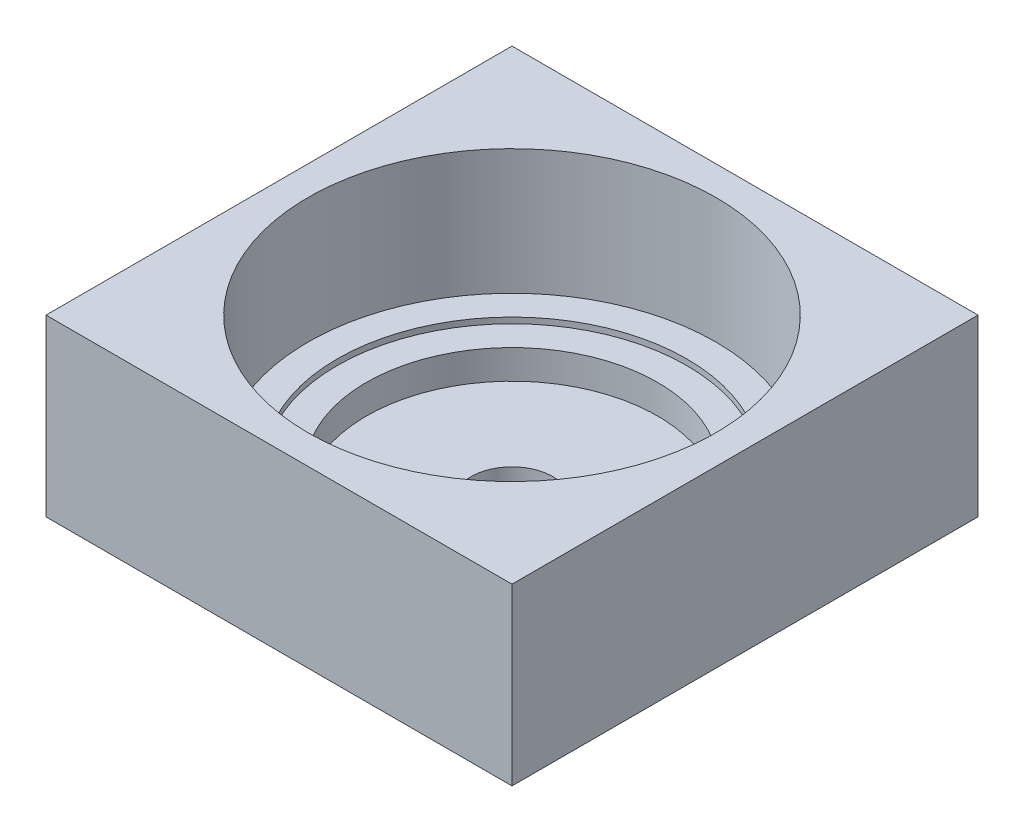
from build123d import *

# Parameters (mm, degrees)
SKETCH_1_W      = 160
SKETCH_1_H      = 160
EXTRUDE_1_DEPTH = 60


with BuildPart() as part:
    # 草圖1 → 填料-伸長1 (new body)
    with BuildSketch(Plane(origin=(0, 0, 0), x_dir=(1, 0, 0), z_dir=(0, 1, 0))):
        Rectangle(SKETCH_1_W, SKETCH_1_H)
    extrude(amount=EXTRUDE_1_DEPTH)

    # 草圖2 → 除料-旋轉1 (revolve, cut)
    with BuildSketch(Plane.XY):
        Polygon((0, 0), (14, 0), (14, 5), (50, 5), (50, 15), (60, 15), (60, 17), (70, 17), (70, 60), (0, 60), align=None)
    revolve(axis=Axis((0, 77.889426339, 0), (0, -1, 0)), mode=Mode.SUBTRACT)


solid = part.part
